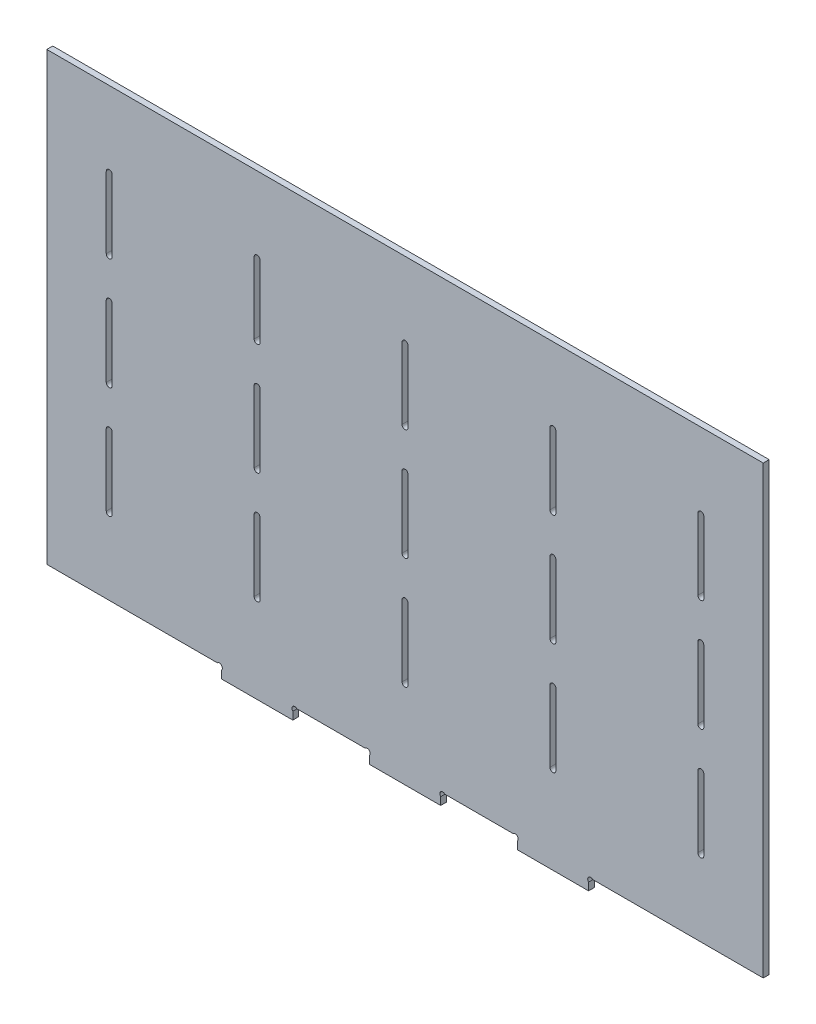
from build123d import *

# Parameters (mm, degrees)
SKETCH1_W                     = 382.775
SKETCH1_H                     = 238.275
BOSS_EXTRUDE1_DEPTH           = 1.5875
SKETCH3_W                     = 38.1
SKETCH3_H                     = 6.35
WELD_TABS_EXTRUDE_DEPTH       = 3.175
SKETCH4_R                     = 1.5875
WELD_TABS_TEAR_DROP_CUT_DEPTH = 3.175
WELD_TABS_CUTOUT_DEPTH        = 3.175


with BuildPart() as part:
    # Sketch1 → Boss-Extrude1 (new body, symmetric)
    with BuildSketch(Plane.XY):
        with Locations((-158.05, 122.3125)):
            Rectangle(SKETCH1_W, SKETCH1_H)
    extrude(amount=BOSS_EXTRUDE1_DEPTH, both=True)

    # Sketch3 → Weld Tabs Extrude (add)
    with BuildSketch(Plane.XY.offset(1.5875)):
        with Locations((-237.075, 0)):
            Rectangle(SKETCH3_W, SKETCH3_H)
        with Locations((-158.05, 0)):
            Rectangle(SKETCH3_W, SKETCH3_H)
        with Locations((-79.025, 0)):
            Rectangle(SKETCH3_W, SKETCH3_H)
    extrude(amount=-WELD_TABS_EXTRUDE_DEPTH)

    # Sketch4 → Weld Tabs Tear Drop Cut (cut)
    with BuildSketch(Plane.XY.offset(1.5875)):
        with Locations((-257.247532015, 2.052467985)):
            Circle(SKETCH4_R)
        with Locations((-216.902467985, 2.052467985)):
            Circle(SKETCH4_R)
        with Locations((-178.222532015, 2.052467985)):
            Circle(SKETCH4_R)
        with Locations((-137.877467985, 2.052467985)):
            Circle(SKETCH4_R)
        with Locations((-99.197532015, 2.052467985)):
            Circle(SKETCH4_R)
        with Locations((-58.852467985, 2.052467985)):
            Circle(SKETCH4_R)
    extrude(amount=-WELD_TABS_TEAR_DROP_CUT_DEPTH, mode=Mode.SUBTRACT)

    # Sketch6 → Weld Tabs Cutout (cut)
    with BuildSketch(Plane.XY.offset(1.5875)):
        with BuildLine():
            Line((-238.6625, 200.93125), (-238.6625, 162.83125))
            ThreePointArc((-238.6625, 162.83125), (-237.075, 161.24375), (-235.4875, 162.83125))
            Line((-235.4875, 162.83125), (-235.4875, 200.93125))
            ThreePointArc((-235.4875, 200.93125), (-237.075, 202.51875), (-238.6625, 200.93125))
        make_face()
        with BuildLine():
            Line((-317.6875, 200.93125), (-317.6875, 162.83125))
            ThreePointArc((-317.6875, 162.83125), (-316.1, 161.24375), (-314.5125, 162.83125))
            Line((-314.5125, 162.83125), (-314.5125, 200.93125))
            ThreePointArc((-314.5125, 200.93125), (-316.1, 202.51875), (-317.6875, 200.93125))
        make_face()
        with BuildLine():
            Line((-159.6375, 200.93125), (-159.6375, 162.83125))
            ThreePointArc((-159.6375, 162.83125), (-158.05, 161.24375), (-156.4625, 162.83125))
            Line((-156.4625, 162.83125), (-156.4625, 200.93125))
            ThreePointArc((-156.4625, 200.93125), (-158.05, 202.51875), (-159.6375, 200.93125))
        make_face()
        with BuildLine():
            Line((-80.6125, 200.93125), (-80.6125, 162.83125))
            ThreePointArc((-80.6125, 162.83125), (-79.025, 161.24375), (-77.4375, 162.83125))
            Line((-77.4375, 162.83125), (-77.4375, 200.93125))
            ThreePointArc((-77.4375, 200.93125), (-79.025, 202.51875), (-80.6125, 200.93125))
        make_face()
        with BuildLine():
            Line((-1.5875, 200.93125), (-1.5875, 162.83125))
            ThreePointArc((-1.5875, 162.83125), (0, 161.24375), (1.5875, 162.83125))
            Line((1.5875, 162.83125), (1.5875, 200.93125))
            ThreePointArc((1.5875, 200.93125), (0, 202.51875), (-1.5875, 200.93125))
        make_face()
        with BuildLine():
            Line((-238.6625, 141.3625), (-238.6625, 103.2625))
            ThreePointArc((-238.6625, 103.2625), (-237.075, 101.675), (-235.4875, 103.2625))
            Line((-235.4875, 103.2625), (-235.4875, 141.3625))
            ThreePointArc((-235.4875, 141.3625), (-237.075, 142.95), (-238.6625, 141.3625))
        make_face()
        with BuildLine():
            Line((-159.6375, 141.3625), (-159.6375, 103.2625))
            ThreePointArc((-159.6375, 103.2625), (-158.05, 101.675), (-156.4625, 103.2625))
            Line((-156.4625, 103.2625), (-156.4625, 141.3625))
            ThreePointArc((-156.4625, 141.3625), (-158.05, 142.95), (-159.6375, 141.3625))
        make_face()
        with BuildLine():
            Line((-80.6125, 141.3625), (-80.6125, 103.2625))
            ThreePointArc((-80.6125, 103.2625), (-79.025, 101.675), (-77.4375, 103.2625))
            Line((-77.4375, 103.2625), (-77.4375, 141.3625))
            ThreePointArc((-77.4375, 141.3625), (-79.025, 142.95), (-80.6125, 141.3625))
        make_face()
        with BuildLine():
            Line((-1.5875, 141.3625), (-1.5875, 103.2625))
            ThreePointArc((-1.5875, 103.2625), (0, 101.675), (1.5875, 103.2625))
            Line((1.5875, 103.2625), (1.5875, 141.3625))
            ThreePointArc((1.5875, 141.3625), (0, 142.95), (-1.5875, 141.3625))
        make_face()
        with BuildLine():
            Line((-238.6625, 81.79375), (-238.6625, 43.69375))
            ThreePointArc((-238.6625, 43.69375), (-237.075, 42.10625), (-235.4875, 43.69375))
            Line((-235.4875, 43.69375), (-235.4875, 81.79375))
            ThreePointArc((-235.4875, 81.79375), (-237.075, 83.38125), (-238.6625, 81.79375))
        make_face()
        with BuildLine():
            Line((-159.6375, 81.79375), (-159.6375, 43.69375))
            ThreePointArc((-159.6375, 43.69375), (-158.05, 42.10625), (-156.4625, 43.69375))
            Line((-156.4625, 43.69375), (-156.4625, 81.79375))
            ThreePointArc((-156.4625, 81.79375), (-158.05, 83.38125), (-159.6375, 81.79375))
        make_face()
        with BuildLine():
            Line((-80.6125, 81.79375), (-80.6125, 43.69375))
            ThreePointArc((-80.6125, 43.69375), (-79.025, 42.10625), (-77.4375, 43.69375))
            Line((-77.4375, 43.69375), (-77.4375, 81.79375))
            ThreePointArc((-77.4375, 81.79375), (-79.025, 83.38125), (-80.6125, 81.79375))
        make_face()
        with BuildLine():
            Line((-1.5875, 81.79375), (-1.5875, 43.69375))
            ThreePointArc((-1.5875, 43.69375), (0, 42.10625), (1.5875, 43.69375))
            Line((1.5875, 43.69375), (1.5875, 81.79375))
            ThreePointArc((1.5875, 81.79375), (0, 83.38125), (-1.5875, 81.79375))
        make_face()
        with BuildLine():
            Line((-317.6875, 141.3625), (-317.6875, 103.2625))
            ThreePointArc((-317.6875, 103.2625), (-316.1, 101.675), (-314.5125, 103.2625))
            Line((-314.5125, 103.2625), (-314.5125, 141.3625))
            ThreePointArc((-314.5125, 141.3625), (-316.1, 142.95), (-317.6875, 141.3625))
        make_face()
        with BuildLine():
            Line((-317.6875, 81.79375), (-317.6875, 43.69375))
            ThreePointArc((-317.6875, 43.69375), (-316.1, 42.10625), (-314.5125, 43.69375))
            Line((-314.5125, 43.69375), (-314.5125, 81.79375))
            ThreePointArc((-314.5125, 81.79375), (-316.1, 83.38125), (-317.6875, 81.79375))
        make_face()
    extrude(amount=-WELD_TABS_CUTOUT_DEPTH, mode=Mode.SUBTRACT)


solid = part.part
